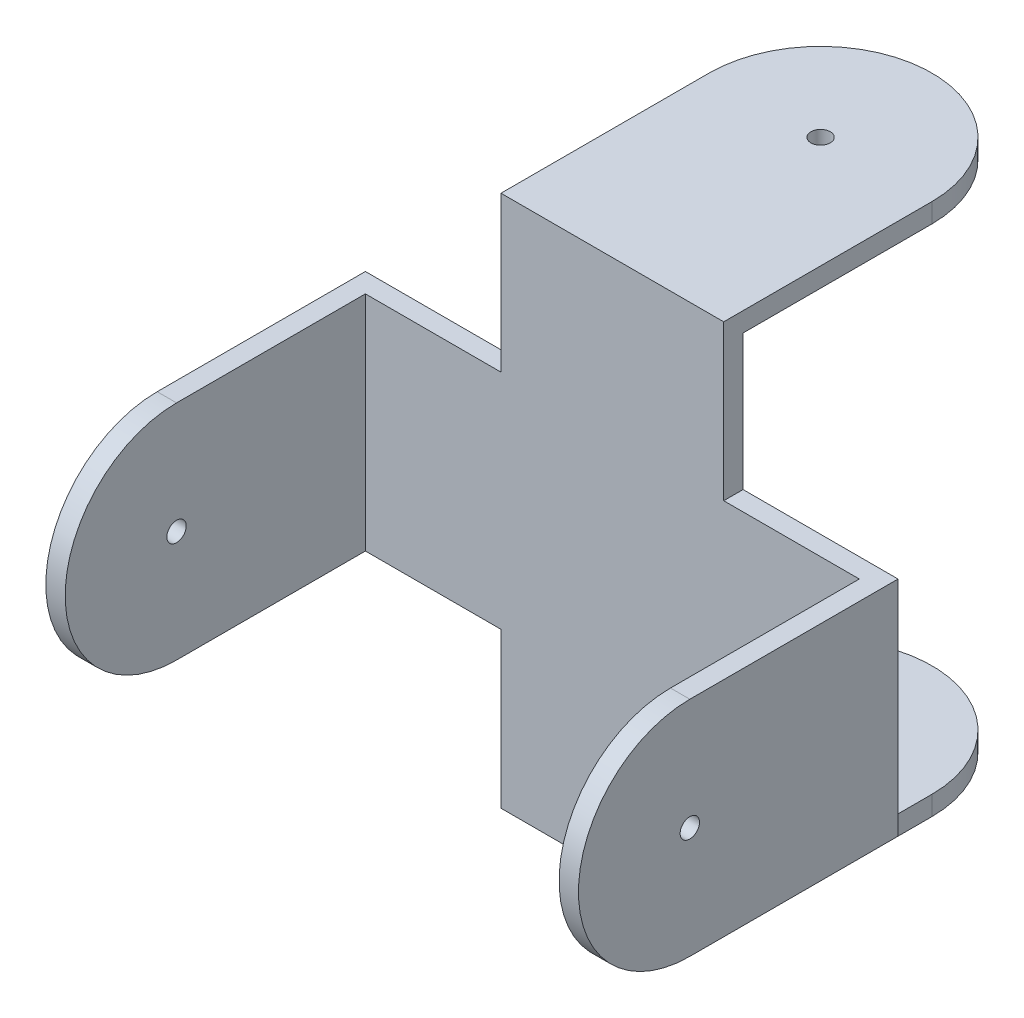
from build123d import *

# Parameters (mm, degrees)
EXTRUDE_1_DEPTH     = 2
EXTRUDE_2_DEPTH     = 2
SKETCH_4_R          = 1
CUT_EXTRUDE_1_DEPTH = 2
EXTRUDE_4_DEPTH     = 2
SKETCH_8_R          = 1
CUT_EXTRUDE_3_DEPTH = 2


with BuildPart() as part:
    # 草图1 → 凸台-拉伸1 (new body)
    with BuildSketch(Plane.XY):
        Polygon((27.5, -11.5), (27.5, 11.5), (11.5, 11.5), (11.5, 27.5), (-11.5, 27.5), (-11.5, 11.5), (-27.5, 11.5), (-27.5, -11.5), (-11.5, -11.5), (-11.5, -27.5), (11.5, -27.5), (11.5, -11.5), align=None)
    extrude(amount=EXTRUDE_1_DEPTH)

    # 草图3 → 凸台-拉伸2 (add)
    with BuildSketch(Plane(origin=(0, 27.5, 0), x_dir=(1, 0, 0), z_dir=(0, 1, 0))):
        with BuildLine():
            Line((-11.5, -2), (11.5, -2))
            Line((11.5, -2), (11.5, 19.5))
            ThreePointArc((11.5, 19.5), (0, 31), (-11.5, 19.5))
            Line((-11.5, 19.5), (-11.5, -2))
        make_face()
    extrude_2 = extrude(amount=-EXTRUDE_2_DEPTH)

    # 草图4 → 切除-拉伸1 (cut)
    with BuildSketch(Plane(origin=(0, 27.5, 0), x_dir=(1, 0, 0), z_dir=(0, 1, 0))):
        with Locations((0, 19.5)):
            Circle(SKETCH_4_R)
    cut_extrude_1 = extrude(amount=-CUT_EXTRUDE_1_DEPTH, mode=Mode.SUBTRACT)

    # 镜向2: 凸台-拉伸2, 切除-拉伸1 across plane
    add(extrude_2.mirror(Plane.ZX))
    add(cut_extrude_1.mirror(Plane.ZX), mode=Mode.SUBTRACT)

    # 草图7 → 凸台-拉伸4 (add)
    with BuildSketch(Plane.ZY.offset(27.5)):
        with BuildLine():
            Line((0, 11.5), (21.5, 11.5))
            ThreePointArc((21.5, 11.5), (33, 0), (21.5, -11.5))
            Line((21.5, -11.5), (0, -11.5))
            Line((0, -11.5), (0, 11.5))
        make_face()
    extrude_4 = extrude(amount=-EXTRUDE_4_DEPTH)

    # 草图8 → 切除-拉伸3 (cut)
    with BuildSketch(Plane.ZY.offset(27.5)):
        with Locations((21.5, 0)):
            Circle(SKETCH_8_R)
    cut_extrude_3 = extrude(amount=-CUT_EXTRUDE_3_DEPTH, mode=Mode.SUBTRACT)

    # 镜向4: 凸台-拉伸4, 切除-拉伸3 across plane
    add(extrude_4.mirror(Plane(origin=(0, 0, 0), x_dir=(0, 0, 1), z_dir=(1, 0, 0))))
    add(cut_extrude_3.mirror(Plane(origin=(0, 0, 0), x_dir=(0, 0, 1), z_dir=(1, 0, 0))), mode=Mode.SUBTRACT)


solid = part.part
